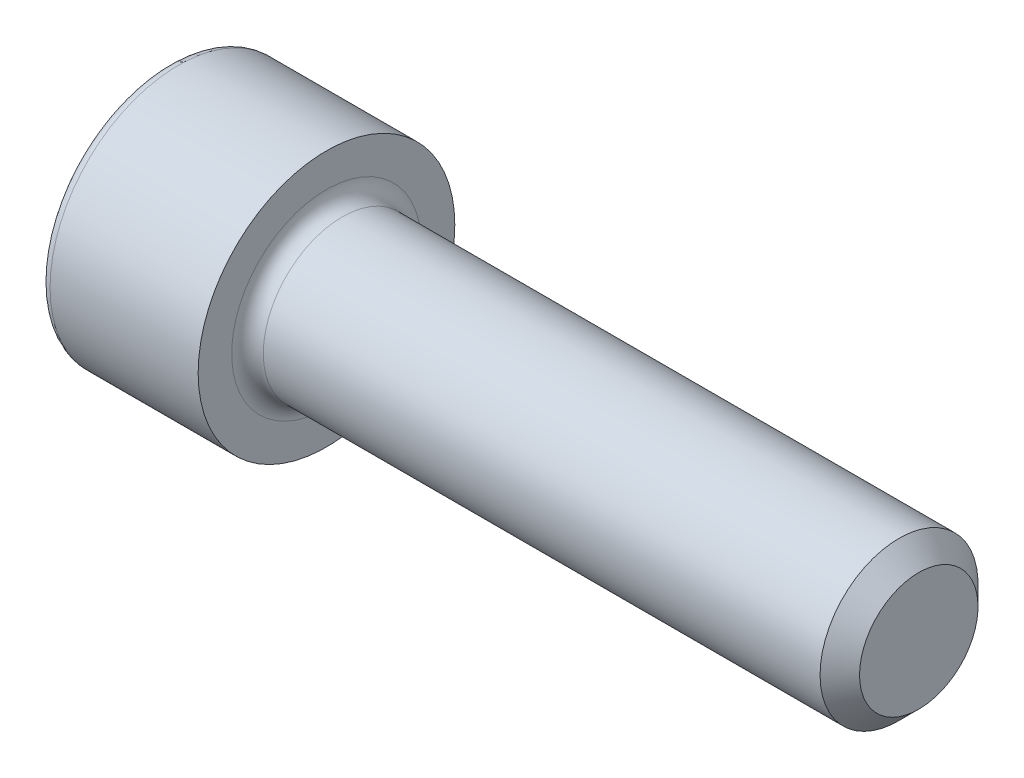
from build123d import *

# Parameters (mm, degrees)
FILLET1_R   = 0.8
FILLET2_R   = 0.5
HEX_2_DEPTH = 12.573


with BuildPart() as part:
    # BodySke → Base-Revolve (revolve)
    with BuildSketch(Plane.XY):
        Polygon((0, 0), (0, 6.5), (8, 6.5), (8, 4), (37, 4), (38, 3), (38, 0), align=None)
    revolve(axis=Axis((-31.75, 0, 0), (1, 0, 0)))

    # Fillet1
    fillet1_edges = [part.edges().sort_by_distance(p)[0] for p in [
        (8, -4, 0),
    ]]
    fillet(fillet1_edges, radius=FILLET1_R)

    # Fillet2
    fillet2_edges = [part.edges().sort_by_distance(p)[0] for p in [
        (0, -6.5, 0),
    ]]
    fillet(fillet2_edges, radius=FILLET2_R)

    # Sketch2 → Hex-PreBroach (revolve, cut)
    with BuildSketch(Plane.XY):
        Polygon((0, 2.8475), (12.573, 2.8475), (14.217004892, 0), (0, 0), align=None)
    revolve(axis=Axis((0, 0, 0), (1, 0, 0)), mode=Mode.SUBTRACT)

    # Sketch3 → Hex 2 (cut)
    with BuildSketch(Plane(origin=(0, 0, 0), x_dir=(0, 0.5, 0.866025404), z_dir=(-1, 0, 0))):
        Polygon((1.644004892, 2.8475), (-1.644004892, 2.8475), (-3.288009783, 0), (-1.644004892, -2.8475), (1.644004892, -2.8475), (3.288009783, 0), align=None)
    extrude(amount=-HEX_2_DEPTH, mode=Mode.SUBTRACT)


solid = part.part
